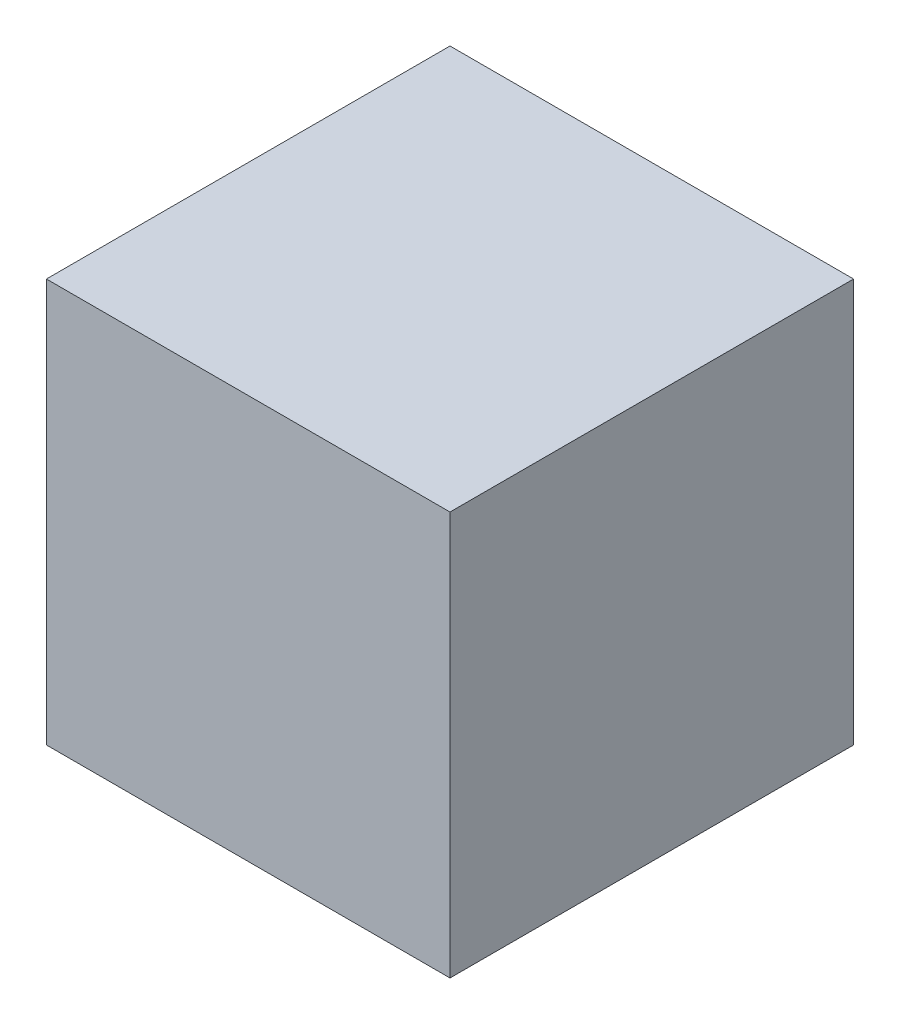
from build123d import *

# Parameters (mm, degrees)
SKETCH_2_W      = 0.1
SKETCH_2_H      = 0.1
EXTRUDE_1_DEPTH = 0.05


with BuildPart() as part:
    # 草图2 → 凸台-拉伸1 (new body, symmetric)
    with BuildSketch(Plane.XY):
        Rectangle(SKETCH_2_W, SKETCH_2_H)
    extrude(amount=EXTRUDE_1_DEPTH, both=True)


solid = part.part
